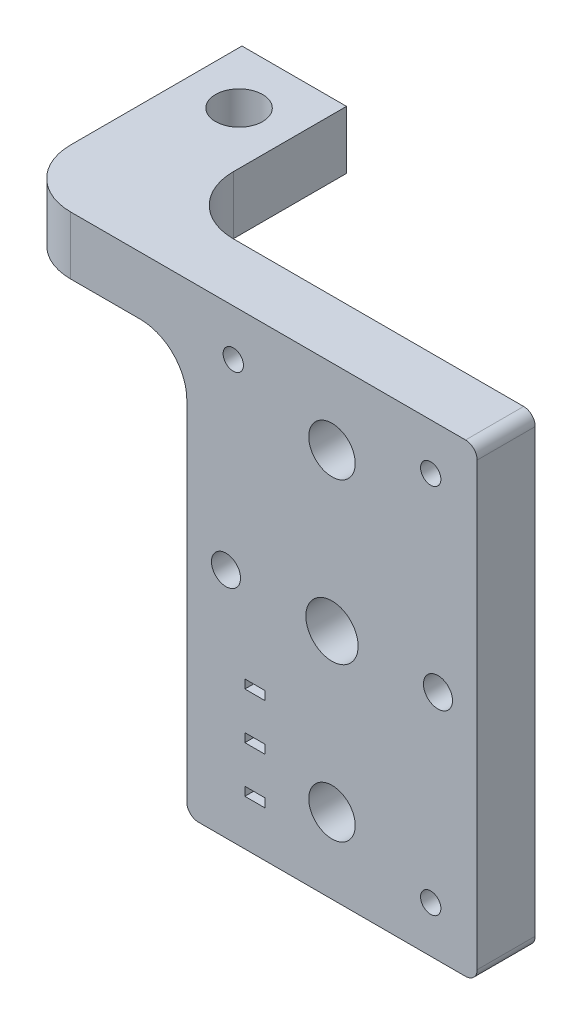
from build123d import *

# Parameters (mm, degrees)
ESBO_O1_W                     = 50
ESBO_O1_H                     = 80
RESSALTO_EXTRUS_O1_DEPTH      = 5
ESBO_O2_R                     = 4.5
ESBO_O2_R_2                   = 4
ESBO_O2_R_3                   = 2.5
CORTE_EXTRUS_O1_DEPTH         = 10
ESBO_O3_W                     = 3.5
ESBO_O3_H                     = 1.5
CORTE_EXTRUS_O2_DEPTH         = 22
ESBO_O4_R                     = 1.75
CORTE_EXTRUS_O3_DEPTH         = 10
FILETE1_R                     = 2
ESBO_O6_W                     = 30
ESBO_O6_H                     = 10
RESSALTO_EXTRUS_O2_DEPTH      = 29.5
RESSALTO_EXTRUS_O2_DEPTH_BACK = 10
ESBO_O7_R                     = 4.05
CORTE_EXTRUS_O4_DEPTH         = 50
ESBO_O8_W                     = 12
ESBO_O8_H                     = 29.5
CORTE_EXTRUS_O5_DEPTH         = 50
FILETE2_R                     = 10
FILETE3_R                     = 8


with BuildPart() as part:
    # Esboço1 → Ressalto-extrusão1 (new body, symmetric)
    with BuildSketch(Plane.XY):
        Rectangle(ESBO_O1_W, ESBO_O1_H)
    extrude(amount=RESSALTO_EXTRUS_O1_DEPTH, both=True)

    # Esboço2 → Corte-extrusão1 (cut)
    with BuildSketch(Plane.XY.offset(5)):
        Circle(ESBO_O2_R)
        with Locations((0, 27)):
            Circle(ESBO_O2_R_2)
        with Locations((0, -27)):
            Circle(ESBO_O2_R_2)
        with Locations((18.25, 0)):
            Circle(ESBO_O2_R_3)
        with Locations((-18.25, 0)):
            Circle(ESBO_O2_R_3)
    extrude(amount=-CORTE_EXTRUS_O1_DEPTH, mode=Mode.SUBTRACT)

    # Esboço3 → Corte-extrusão2 (cut)
    with BuildSketch(Plane.XY.offset(5)):
        with Locations((-13.25, -31.39)):
            Rectangle(ESBO_O3_W, ESBO_O3_H)
        with Locations((-13.25, -23.39)):
            Rectangle(ESBO_O3_W, ESBO_O3_H)
        with Locations((-13.25, -15.39)):
            Rectangle(ESBO_O3_W, ESBO_O3_H)
    extrude(amount=-CORTE_EXTRUS_O2_DEPTH, mode=Mode.SUBTRACT)

    # Esboço4 → Corte-extrusão3 (cut)
    with BuildSketch(Plane.XY.offset(5)):
        with Locations((-17, 32)):
            Circle(ESBO_O4_R)
        with Locations((17, 32)):
            Circle(ESBO_O4_R)
        with Locations((17, -32)):
            Circle(ESBO_O4_R)
    extrude(amount=-CORTE_EXTRUS_O3_DEPTH, mode=Mode.SUBTRACT)

    # Filete1
    filete1_edges = [part.edges().sort_by_distance(p)[0] for p in [
        (25, -40, 0),
        (-25, -40, 0),
        (25, 40, 0),
    ]]
    fillet(filete1_edges, radius=FILETE1_R)

    # Esboço6 → Ressalto-extrusão2 (add, two sides)
    with BuildSketch(Plane(origin=(0, 0, -5), x_dir=(-1, 0, 0), z_dir=(0, 0, -1))) as ressalto_extrus_o2_sk:
        with Locations((40, 35)):
            Rectangle(ESBO_O6_W, ESBO_O6_H)
    extrude(amount=RESSALTO_EXTRUS_O2_DEPTH)
    extrude(ressalto_extrus_o2_sk.sketch, amount=-RESSALTO_EXTRUS_O2_DEPTH_BACK)

    # Esboço7 → Corte-extrusão4 (cut)
    with BuildSketch(Plane(origin=(0, 40, 0), x_dir=(1, 0, 0), z_dir=(0, 1, 0))):
        with Locations((-46, 25)):
            Circle(ESBO_O7_R)
    extrude(amount=-CORTE_EXTRUS_O4_DEPTH, mode=Mode.SUBTRACT)

    # Esboço8 → Corte-extrusão5 (cut)
    with BuildSketch(Plane(origin=(0, 40, 0), x_dir=(1, 0, 0), z_dir=(0, 1, 0))):
        with Locations((-31, 19.75)):
            Rectangle(ESBO_O8_W, ESBO_O8_H)
    extrude(amount=-CORTE_EXTRUS_O5_DEPTH, mode=Mode.SUBTRACT)

    # Filete2
    filete2_edges = [part.edges().sort_by_distance(p)[0] for p in [
        (-55, 35, 5),
        (-37, 35, -5),
    ]]
    fillet(filete2_edges, radius=FILETE2_R)

    # Filete3
    filete3_edges = [part.edges().sort_by_distance(p)[0] for p in [
        (-25, 30, 0),
    ]]
    fillet(filete3_edges, radius=FILETE3_R)


solid = part.part
